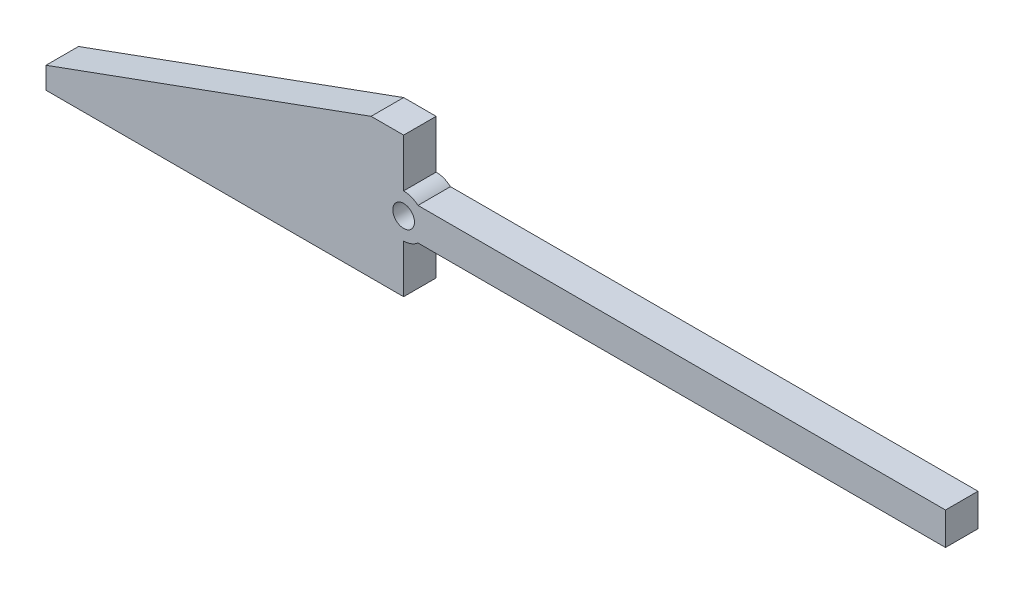
from build123d import *

# Parameters (mm, degrees)
SKETCH_1_R      = 1
EXTRUDE_1_DEPTH = 3


with BuildPart() as part:
    # Эскиз1 → Бобышка-Вытянуть1 (new body)
    with BuildSketch(Plane.XY):
        with BuildLine():
            Line((0, 0), (0, 2))
            Line((0, 2), (30, 12.919107028))
            Line((30, 12.919107028), (33, 12.919107028))
            Line((33, 12.919107028), (33, 8.459553514))
            ThreePointArc((33, 8.459553514), (33.707106781, 8.330382207), (34.322875656, 7.959553514))
            Line((34.322875656, 7.959553514), (83, 7.959553514))
            Line((83, 7.959553514), (83, 4.959553514))
            Line((83, 4.959553514), (34.322875656, 4.959553514))
            ThreePointArc((34.322875656, 4.959553514), (33.707106781, 4.588724821), (33, 4.459553514))
            Line((33, 4.459553514), (33, 0))
            Line((33, 0), (0, 0))
        make_face()
        with Locations((33, 6.459553514)):
            Circle(SKETCH_1_R, mode=Mode.SUBTRACT)
    extrude(amount=EXTRUDE_1_DEPTH)


solid = part.part
